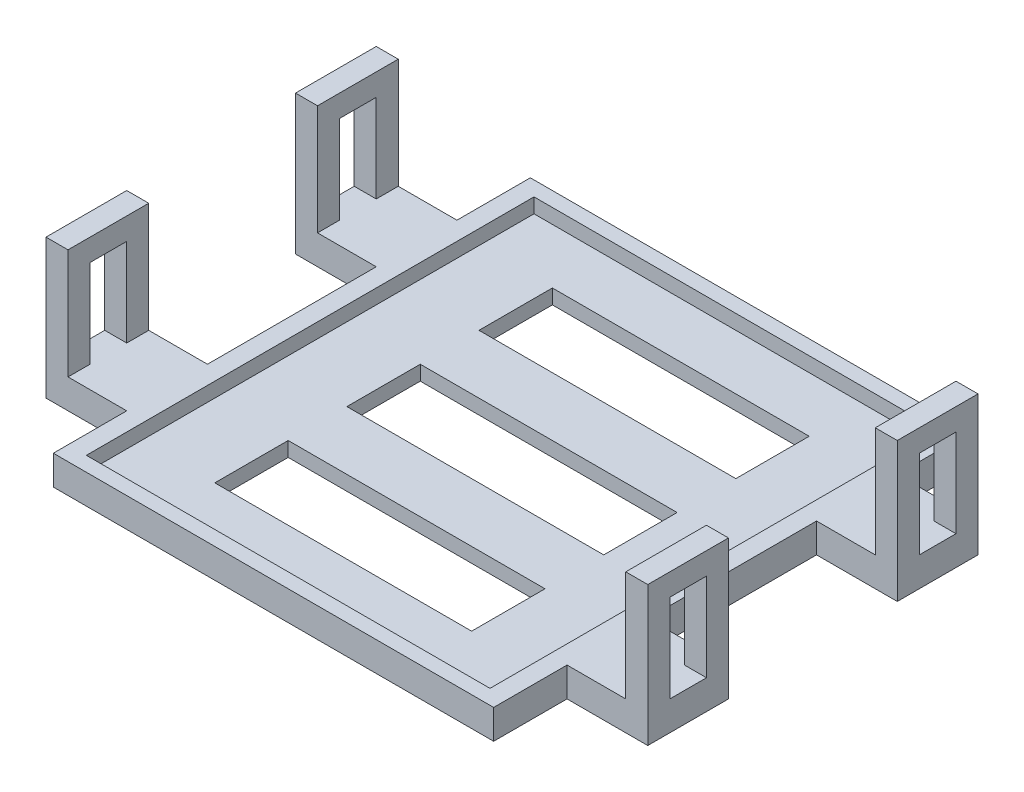
from build123d import *

# Parameters (mm, degrees)
SALIENTE_EXTRUIR1_DEPTH    = 4
CROQUIS2_W                 = 55
CROQUIS2_H                 = 61
CORTAR_EXTRUIR1_DEPTH      = 2
CROQUIS12_W                = 3
CROQUIS12_H                = 11
SALIENTE_EXTRUIR2_DEPTH    = 15
CROQUIS13_W                = 5
CROQUIS13_H                = 12
CORTAR_EXTRUIR8_DEPTH      = 80
CORTAR_EXTRUIR8_DEPTH_BACK = 4
CROQUIS14_W                = 5
CROQUIS14_H                = 12
CORTAR_EXTRUIR9_DEPTH      = 80
CORTAR_EXTRUIR9_DEPTH_BACK = 4
CROQUIS15_W                = 35
CROQUIS15_H                = 10
CORTAR_EXTRUIR10_DEPTH     = 20


with BuildPart() as part:
    # Croquis1 → Saliente-Extruir1 (new body)
    with BuildSketch(Plane(origin=(0, 0, 0), x_dir=(1, 0, 0), z_dir=(0, 1, 0))):
        Polygon((30, -32.5), (30, -22.5), (41, -22.5), (41, -11.5), (30, -11.5), (30, 11.5), (41, 11.5), (41, 22.5), (30, 22.5), (30, 32.5), (-30, 32.5), (-30, 22.5), (-41, 22.5), (-41, 11.5), (-30, 11.5), (-30, -11.5), (-41, -11.5), (-41, -22.5), (-30, -22.5), (-30, -32.5), align=None)
    extrude(amount=SALIENTE_EXTRUIR1_DEPTH)

    # Croquis2 → Cortar-Extruir1 (cut)
    with BuildSketch(Plane(origin=(0, 4, 0), x_dir=(1, 0, 0), z_dir=(0, 1, 0))):
        Rectangle(CROQUIS2_W, CROQUIS2_H)
    extrude(amount=-CORTAR_EXTRUIR1_DEPTH, mode=Mode.SUBTRACT)

    # Croquis12 → Saliente-Extruir2 (add)
    with BuildSketch(Plane(origin=(0, 4, 0), x_dir=(1, 0, 0), z_dir=(0, 1, 0))):
        with Locations((-39.5, 17)):
            Rectangle(CROQUIS12_W, CROQUIS12_H)
        with Locations((-39.5, -17)):
            Rectangle(CROQUIS12_W, CROQUIS12_H)
        with Locations((39.5, -17)):
            Rectangle(CROQUIS12_W, CROQUIS12_H)
        with Locations((39.5, 17)):
            Rectangle(CROQUIS12_W, CROQUIS12_H)
    extrude(amount=SALIENTE_EXTRUIR2_DEPTH)

    # Croquis13 → Cortar-Extruir8 (cut, two sides)
    with BuildSketch(Plane.ZY.offset(-38)) as cortar_extruir8_sk:
        with Locations((-17, 10)):
            Rectangle(CROQUIS13_W, CROQUIS13_H)
    extrude(amount=CORTAR_EXTRUIR8_DEPTH, mode=Mode.SUBTRACT)
    extrude(cortar_extruir8_sk.sketch, amount=-CORTAR_EXTRUIR8_DEPTH_BACK, mode=Mode.SUBTRACT)

    # Croquis14 → Cortar-Extruir9 (cut, two sides)
    with BuildSketch(Plane.ZY.offset(-38)) as cortar_extruir9_sk:
        with Locations((17, 10)):
            Rectangle(CROQUIS14_W, CROQUIS14_H)
    extrude(amount=CORTAR_EXTRUIR9_DEPTH, mode=Mode.SUBTRACT)
    extrude(cortar_extruir9_sk.sketch, amount=-CORTAR_EXTRUIR9_DEPTH_BACK, mode=Mode.SUBTRACT)

    # Croquis15 → Cortar-Extruir10 (cut, through all)
    with BuildSketch(Plane(origin=(0, 0, 0), x_dir=(1, 0, 0), z_dir=(0, 1, 0))):
        Rectangle(CROQUIS15_W, CROQUIS15_H)
        with Locations((0, -18)):
            Rectangle(CROQUIS15_W, CROQUIS15_H)
        with Locations((0, 18)):
            Rectangle(CROQUIS15_W, CROQUIS15_H)
    extrude(amount=CORTAR_EXTRUIR10_DEPTH, mode=Mode.SUBTRACT)


solid = part.part
